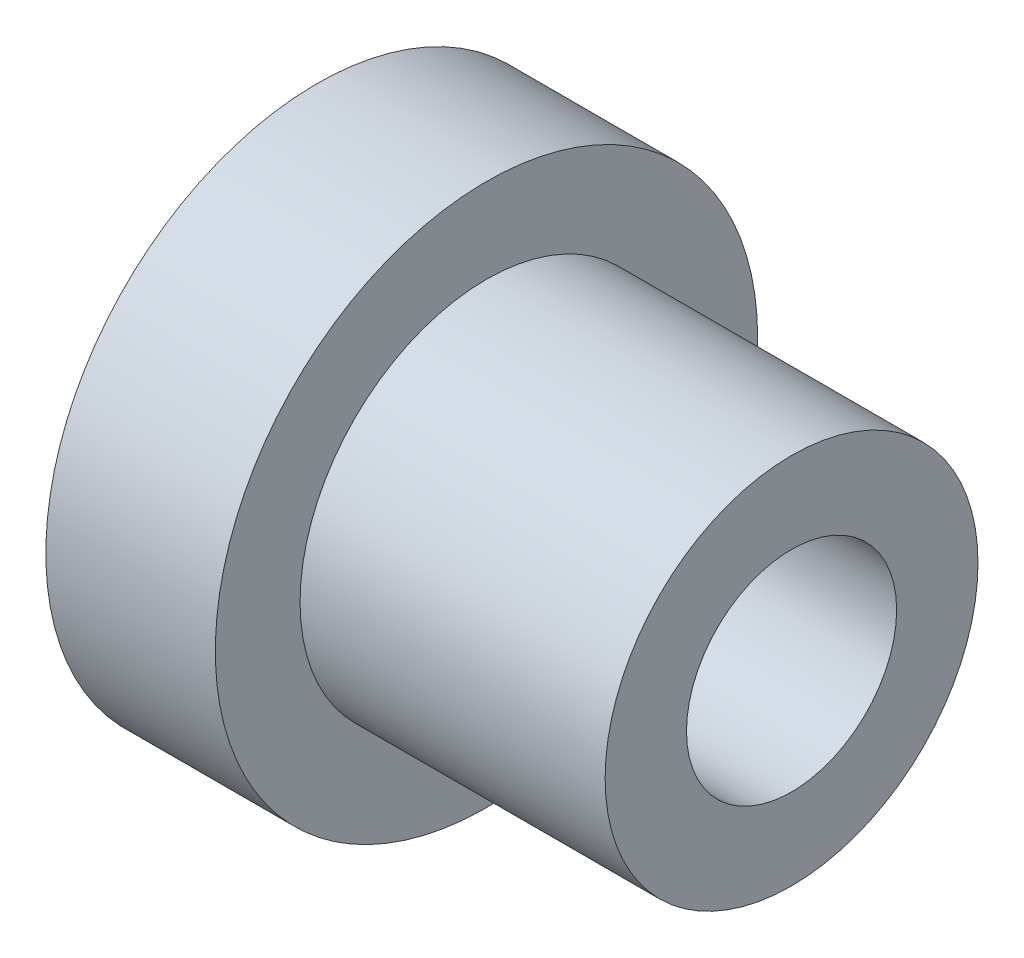
from build123d import *


with BuildPart() as part:
    # Sketch1 → Revolve1 (revolve)
    with BuildSketch(Plane.XY):
        Polygon((-2.85, 5.5), (-2.85, 8), (-7.85, 8), (-7.85, 6), (-5.35, 6), (-5.35, 3.1), (6.15, 3.1), (6.15, 5.5), align=None)
    revolve(axis=Axis((-7.85, 0, 0), (1, 0, 0)))


solid = part.part
